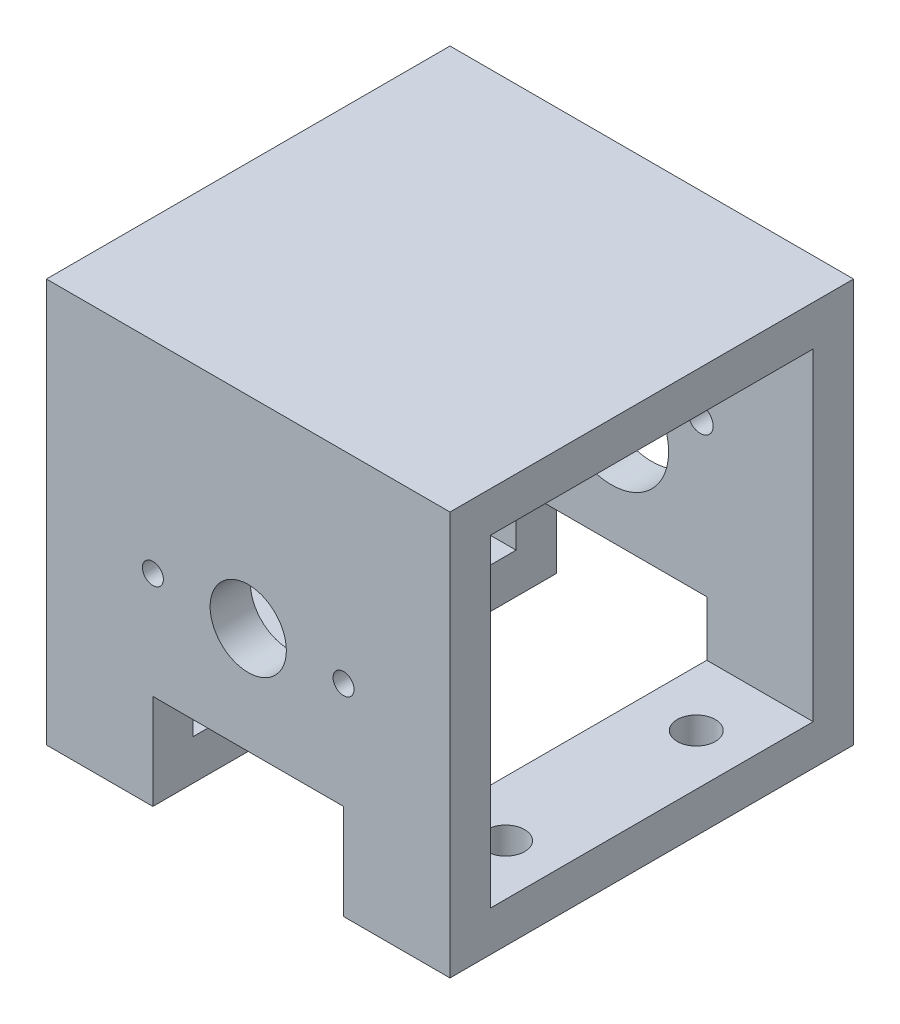
from build123d import *

# Parameters (mm, degrees)
SKETCH1_W                 = 63.5
SKETCH1_H                 = 63.5
BOSS_EXTRUDE1_DEPTH       = 31.75
SHELL1_T                  = -6.35
SKETCH2_W                 = 30
SKETCH2_H                 = 15
CUT_EXTRUDE1_DEPTH        = 32.75
CUT_EXTRUDE1_DEPTH_BACK   = 32.75
SKETCH3_R                 = 6
CUT_EXTRUDE2_DEPTH        = 32.75
M4X0_7_TAPPED_HOLE3_D     = 3.3
M4X0_7_TAPPED_HOLE3_DEPTH = 6.35
SKETCH8_R                 = 9
SKETCH8_R_2               = 2
CUT_EXTRUDE3_DEPTH        = 32.75
SKETCH9_R                 = 3
CUT_EXTRUDE4_DEPTH        = 32.75


with BuildPart() as part:
    # Sketch1 → Boss-Extrude1 (new body, symmetric)
    with BuildSketch(Plane(origin=(0, 0, 0), x_dir=(1, 0, 0), z_dir=(0, 1, 0))):
        Rectangle(SKETCH1_W, SKETCH1_H)
    extrude(amount=BOSS_EXTRUDE1_DEPTH, both=True)

    # Shell1
    shell1_openings = [part.faces().sort_by_distance(p)[0] for p in [
        (-31.75, 0, 0),
        (31.75, 0, 0),
    ]]
    offset(amount=SHELL1_T, openings=shell1_openings, kind=Kind.INTERSECTION)

    # Sketch2 → Cut-Extrude1 (cut, two sides)
    with BuildSketch(Plane.XY) as cut_extrude1_sk:
        with Locations((0, -24.25)):
            Rectangle(SKETCH2_W, SKETCH2_H)
    extrude(amount=CUT_EXTRUDE1_DEPTH, mode=Mode.SUBTRACT)
    extrude(cut_extrude1_sk.sketch, amount=-CUT_EXTRUDE1_DEPTH_BACK, mode=Mode.SUBTRACT)

    # Sketch3 → Cut-Extrude2 (cut, through all)
    with BuildSketch(Plane.XY):
        Circle(SKETCH3_R)
    extrude(amount=CUT_EXTRUDE2_DEPTH, mode=Mode.SUBTRACT)

    # M4x0.7 Tapped Hole3
    with Locations(Plane(origin=(-15, 0, 31.75), x_dir=(1, 0, 0), z_dir=(0, 0, 1))):
        with Locations((0, 0), (30, 0)):
            Hole(M4X0_7_TAPPED_HOLE3_D / 2, depth=M4X0_7_TAPPED_HOLE3_DEPTH)

    # Sketch8 → Cut-Extrude3 (cut, through all)
    with BuildSketch(Plane.XY):
        Circle(SKETCH8_R)
        with Locations((-14, 7)):
            Circle(SKETCH8_R_2)
        with Locations((14, 7)):
            Circle(SKETCH8_R_2)
    extrude(amount=-CUT_EXTRUDE3_DEPTH, mode=Mode.SUBTRACT)

    # Sketch9 → Cut-Extrude4 (cut, through all)
    with BuildSketch(Plane(origin=(0, 0, 0), x_dir=(1, 0, 0), z_dir=(0, 1, 0))):
        with Locations((-23.75, -15)):
            Circle(SKETCH9_R)
        with Locations((23.75, -15)):
            Circle(SKETCH9_R)
        with Locations((23.75, 15)):
            Circle(SKETCH9_R)
        with Locations((-23.75, 15)):
            Circle(SKETCH9_R)
    extrude(amount=-CUT_EXTRUDE4_DEPTH, mode=Mode.SUBTRACT)


solid = part.part
